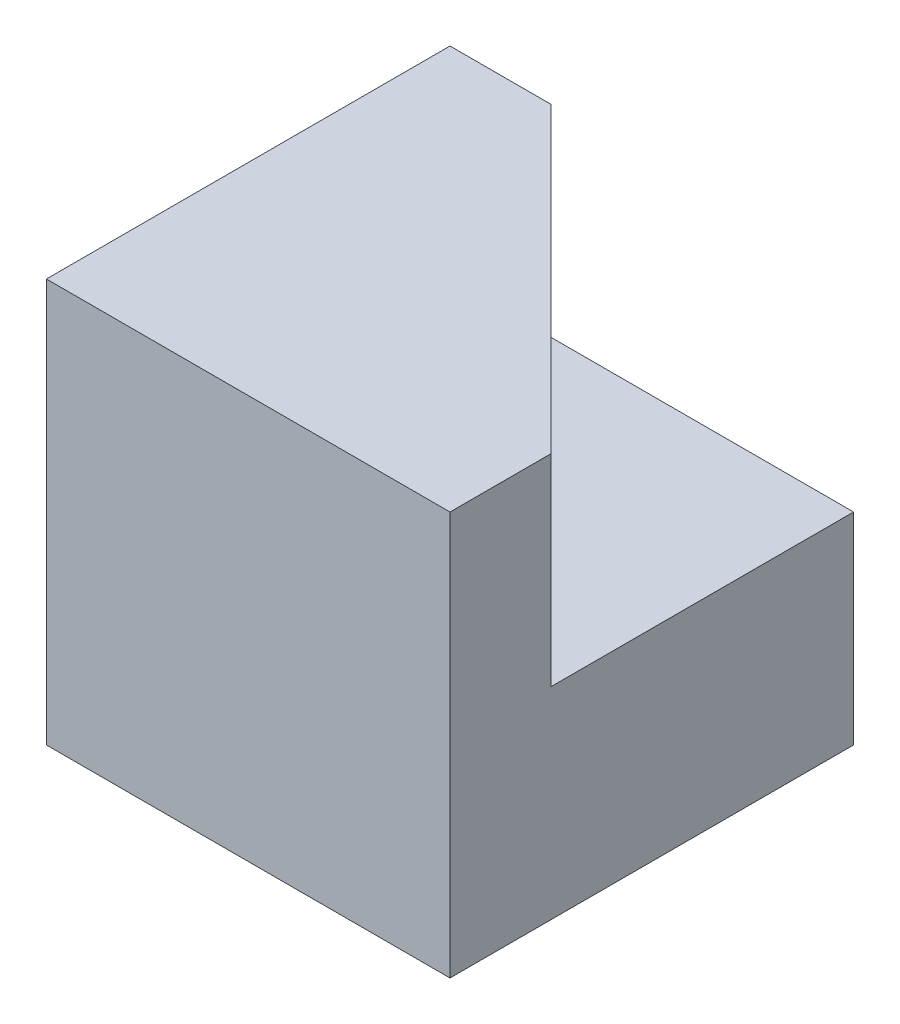
from build123d import *

# Parameters (mm, degrees)
SKETCH1_W           = 40
SKETCH1_H           = 40
BOSS_EXTRUDE1_DEPTH = 40
CUT_EXTRUDE1_DEPTH  = 20


with BuildPart() as part:
    # Sketch1 → Boss-Extrude1 (new body)
    with BuildSketch(Plane.XY):
        with Locations((20, 20)):
            Rectangle(SKETCH1_W, SKETCH1_H)
    extrude(amount=BOSS_EXTRUDE1_DEPTH)

    # Sketch2 → Cut-Extrude1 (cut)
    with BuildSketch(Plane(origin=(0, 40, 0), x_dir=(1, 0, 0), z_dir=(0, 1, 0))):
        Polygon((10, 0), (40, -30), (40, 0), align=None)
    extrude(amount=-CUT_EXTRUDE1_DEPTH, mode=Mode.SUBTRACT)


solid = part.part
